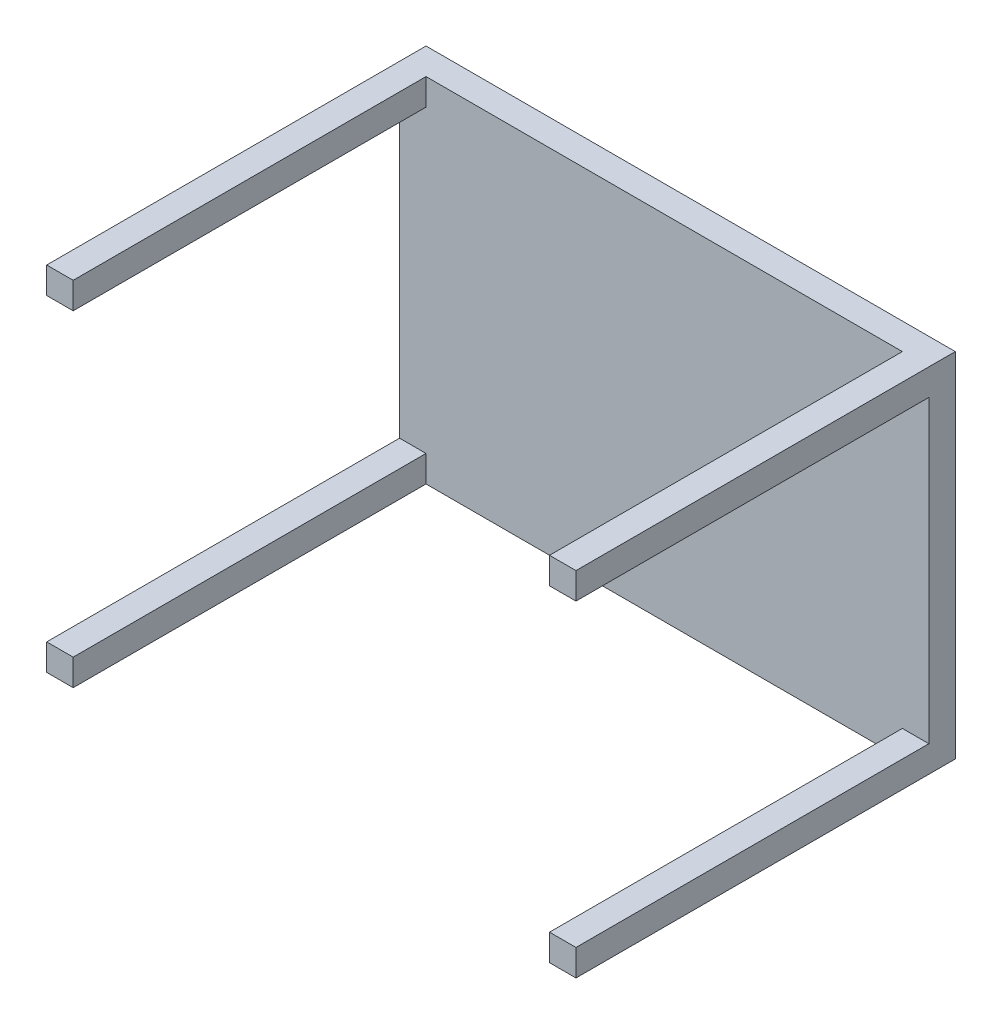
from build123d import *

# Parameters (mm, degrees)
SKETCH1_W           = 600
SKETCH1_H           = 400
BOSS_EXTRUDE1_DEPTH = 30
SKETCH2_W           = 30
SKETCH2_H           = 30
BOSS_EXTRUDE2_DEPTH = 400


with BuildPart() as part:
    # Sketch1 → Boss-Extrude1 (new body)
    with BuildSketch(Plane.XY):
        Rectangle(SKETCH1_W, SKETCH1_H)
    extrude(amount=BOSS_EXTRUDE1_DEPTH)

    # Sketch2 → Boss-Extrude2 (add)
    with BuildSketch(Plane.XY.offset(30)):
        with Locations((285, 185)):
            Rectangle(SKETCH2_W, SKETCH2_H)
        with Locations((-285, 185)):
            Rectangle(SKETCH2_W, SKETCH2_H)
        with Locations((285, -185)):
            Rectangle(SKETCH2_W, SKETCH2_H)
        with Locations((-285, -185)):
            Rectangle(SKETCH2_W, SKETCH2_H)
    extrude(amount=BOSS_EXTRUDE2_DEPTH)


solid = part.part
